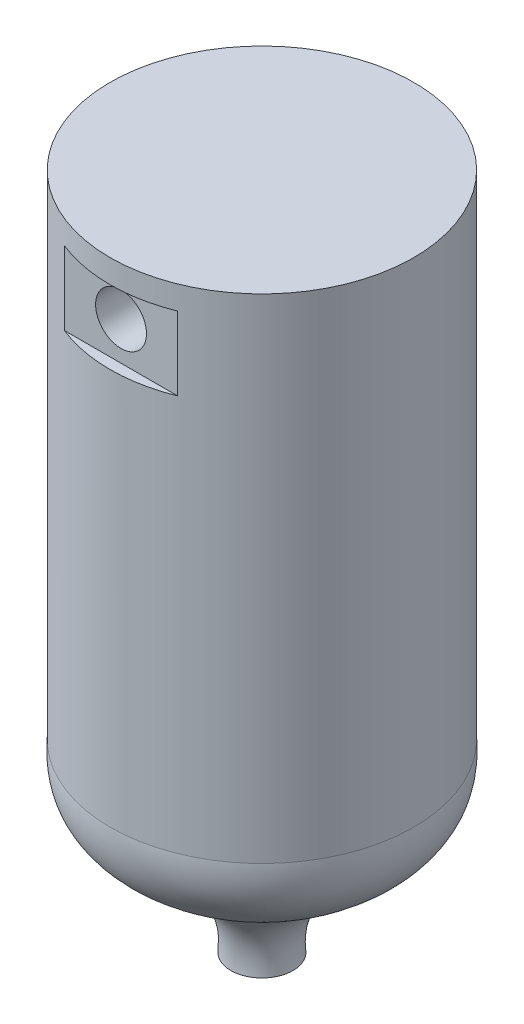
from build123d import *

# Parameters (mm, degrees)
SKETCH3_R               = 0.65
CUT_EXTRUDE1_DEPTH      = 2
CUT_EXTRUDE2_START      = 2
SKETCH4_R               = 0.65
CUT_EXTRUDE2_DEPTH      = 2
CUT_EXTRUDE4_DEPTH      = 5
CUT_EXTRUDE4_DEPTH_BACK = 5
SKETCH6_W               = 0.570635025
SKETCH6_H               = 1.87642035


with BuildPart() as part:
    # Sketch2 → Revolve1 (revolve)
    with BuildSketch(Plane.XY):
        with BuildLine():
            Line((-3.879111396, 0), (-3.879111396, -12))
            Line((-3.879111396, -12), (-3.879111402, -12.602750297))
            add(Edge.make_bspline(
                [(-3.879111402, -12.602750297), (-4.096238593, -15.249180041), (-0.537349984, -14.727809099), (-0.795067133, -17.31657115)],
                knots=[0, 0, 0, 0, 1, 1, 1, 1], degree=3))
            Line((-0.795067133, -17.31657115), (0, -17.31657115))
            Line((0, -17.31657115), (0, 0))
            Line((0, 0), (-3.879111396, 0))
        make_face()
    revolve(axis=Axis((0, 0, 0), (0, -1, 0)))

    # Sketch3 → Cut-Extrude1 (cut)
    with BuildSketch(Plane.XY.offset(3.9)):
        with Locations((0, -1.5)):
            Circle(SKETCH3_R)
    extrude(amount=-CUT_EXTRUDE1_DEPTH, mode=Mode.SUBTRACT)

    # Sketch4 → Cut-Extrude2 (cut)
    with BuildSketch(Plane.XY.offset(-3.9).offset(CUT_EXTRUDE2_START)):
        with Locations((0, -1.5)):
            Circle(SKETCH4_R)
    extrude(amount=-CUT_EXTRUDE2_DEPTH, mode=Mode.SUBTRACT)

    # Sketch6 → Cut-Extrude4 (cut, two sides: drawn at the far end of the back side and taken through both)
    with BuildSketch(Plane(origin=(0, 0, 0), x_dir=(0, 0, -1), z_dir=(1, 0, 0)).offset(-CUT_EXTRUDE4_DEPTH_BACK)):
        with Locations((-3.8850644, -1.538047365)):
            Rectangle(SKETCH6_W, SKETCH6_H)
    extrude(amount=CUT_EXTRUDE4_DEPTH + CUT_EXTRUDE4_DEPTH_BACK, mode=Mode.SUBTRACT)


solid = part.part
